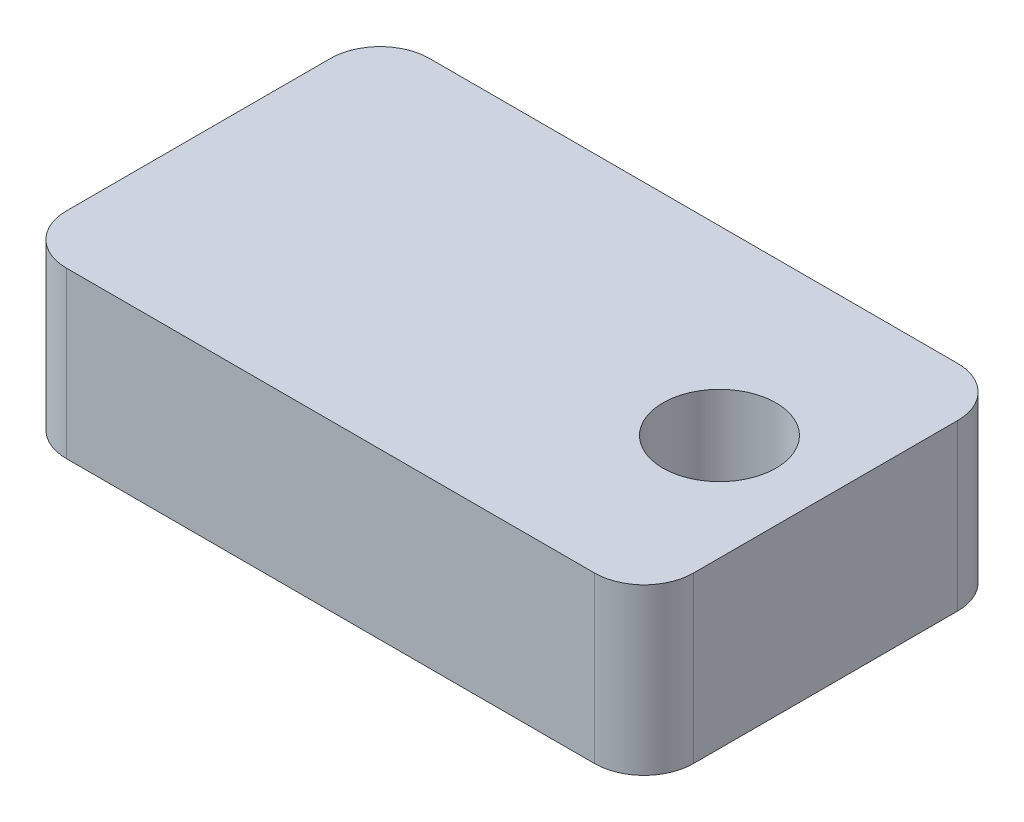
from build123d import *

# Parameters (mm, degrees)
SKETCH1_W           = 38
SKETCH1_H           = 22
SKETCH1_R           = 3.429
BOSS_EXTRUDE1_DEPTH = 10
FILLET1_R           = 3


with BuildPart() as part:
    # Sketch1 → Boss-Extrude1 (new body)
    with BuildSketch(Plane(origin=(0, 0, 0), x_dir=(1, 0, 0), z_dir=(0, 1, 0))):
        Rectangle(SKETCH1_W, SKETCH1_H)
        with Locations((12.571, 0)):
            Circle(SKETCH1_R, mode=Mode.SUBTRACT)
    extrude(amount=BOSS_EXTRUDE1_DEPTH)

    # Fillet1
    fillet1_edges = [part.edges().sort_by_distance(p)[0] for p in [
        (19, 5, 11),
        (-19, 5, 11),
        (-19, 5, -11),
        (19, 5, -11),
    ]]
    fillet(fillet1_edges, radius=FILLET1_R)


solid = part.part
